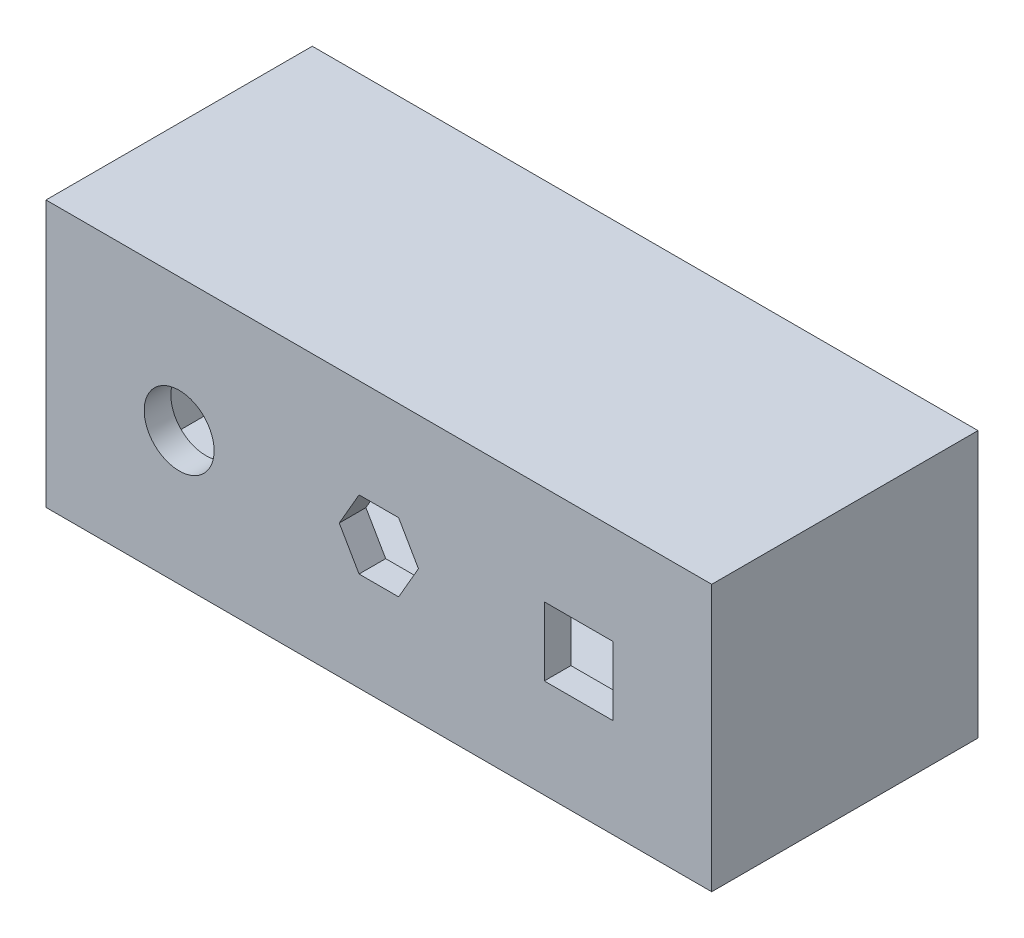
from build123d import *

# Parameters (mm, degrees)
SKETCH5_W           = 500
SKETCH5_H           = 200
BOSS_EXTRUDE2_DEPTH = 200
SHELL2_T            = -20
SKETCH6_R           = 26.25
SKETCH6_W           = 51.5
SKETCH6_H           = 51.5
CUT_EXTRUDE2_DEPTH  = 51.6


with BuildPart() as part:
    # Sketch5 → Boss-Extrude2 (new body)
    with BuildSketch(Plane.XY):
        Rectangle(SKETCH5_W, SKETCH5_H)
    extrude(amount=BOSS_EXTRUDE2_DEPTH)

    # Shell2
    shell2_openings = [part.faces().sort_by_distance(p)[0] for p in [
        (0, 0, 0),
    ]]
    offset(amount=SHELL2_T, openings=shell2_openings, kind=Kind.INTERSECTION)

    # Sketch6 → Cut-Extrude2 (cut)
    with BuildSketch(Plane.XY.offset(200)):
        with Locations((-150, 0)):
            Circle(SKETCH6_R)
        Polygon((14.866769432, 25.75), (-14.866769432, 25.75), (-29.733538863, 0), (-14.866769432, -25.75), (14.866769432, -25.75), (29.733538863, 0), align=None)
        with Locations((150, 0)):
            Rectangle(SKETCH6_W, SKETCH6_H)
    extrude(amount=-CUT_EXTRUDE2_DEPTH, mode=Mode.SUBTRACT)


solid = part.part
